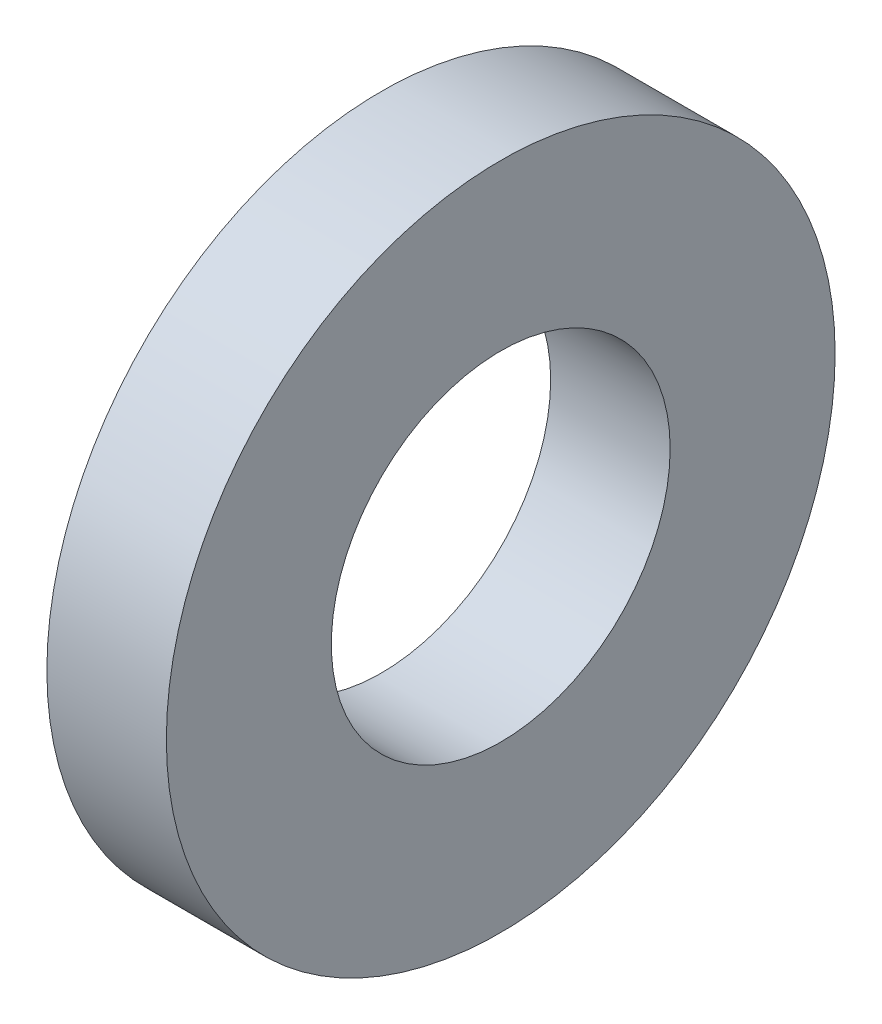
from build123d import *

# Parameters (mm, degrees)
SKETCH1_R           = 4.7625
SKETCH1_R_2         = 2.413
BOSS_EXTRUDE1_DEPTH = 1.7018


with BuildPart() as part:
    # Sketch1 → Boss-Extrude1 (new body)
    with BuildSketch(Plane(origin=(0, 0, 0), x_dir=(0, 0, -1), z_dir=(1, 0, 0))):
        Circle(SKETCH1_R)
        Circle(SKETCH1_R_2, mode=Mode.SUBTRACT)
    extrude(amount=BOSS_EXTRUDE1_DEPTH)


solid = part.part
